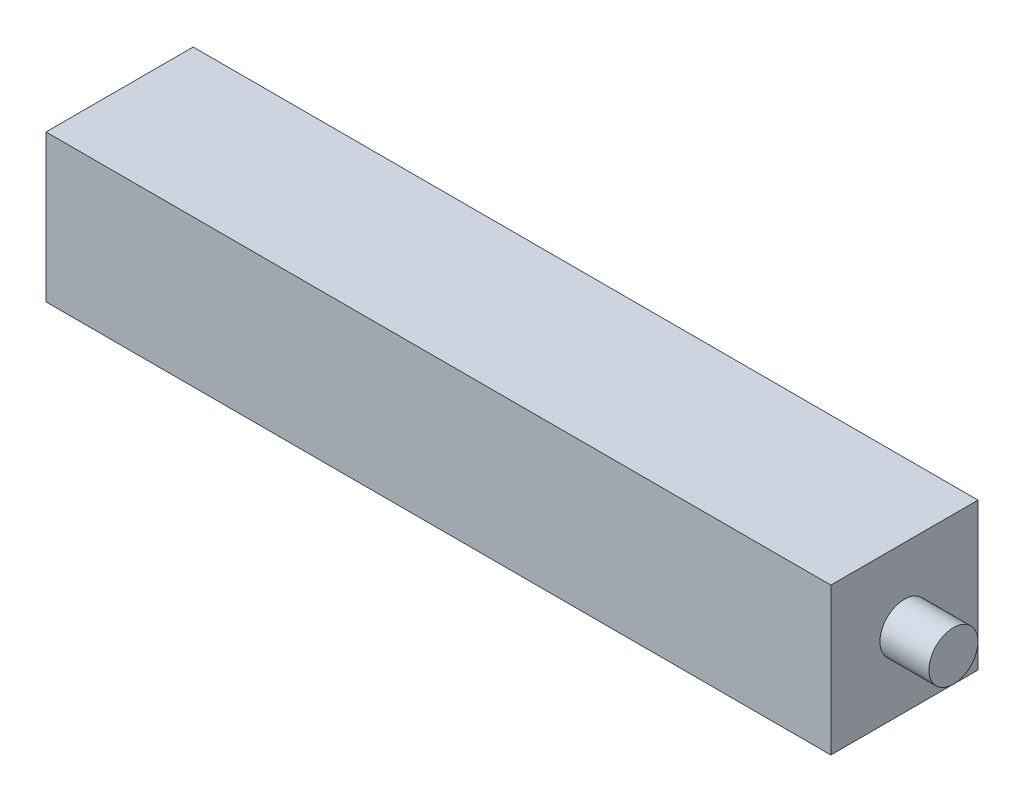
from build123d import *

# Parameters (mm, degrees)
CROQUIS1_W              = 203.2
CROQUIS1_H              = 38.1
SALIENTE_EXTRUIR2_DEPTH = 38.1
CROQUIS2_R              = 6.35
SALIENTE_EXTRUIR3_DEPTH = 12.7
CROQUIS3_R              = 6.35
SALIENTE_EXTRUIR4_DEPTH = 12.7


with BuildPart() as part:
    # Croquis1 → Saliente-Extruir2 (new body)
    with BuildSketch(Plane(origin=(0, 0, 0), x_dir=(1, 0, 0), z_dir=(0, 1, 0))):
        Rectangle(CROQUIS1_W, CROQUIS1_H)
    extrude(amount=SALIENTE_EXTRUIR2_DEPTH)

    # Croquis2 → Saliente-Extruir3 (add)
    with BuildSketch(Plane(origin=(101.6, 0, 0), x_dir=(0, 0, -1), z_dir=(1, 0, 0))):
        with Locations((0, 19.05)):
            Circle(CROQUIS2_R)
    extrude(amount=SALIENTE_EXTRUIR3_DEPTH)

    # Croquis3 → Saliente-Extruir4 (add)
    with BuildSketch(Plane.ZY.offset(101.6)):
        with Locations((0, 19.05)):
            Circle(CROQUIS3_R)
    extrude(amount=SALIENTE_EXTRUIR4_DEPTH)


solid = part.part
